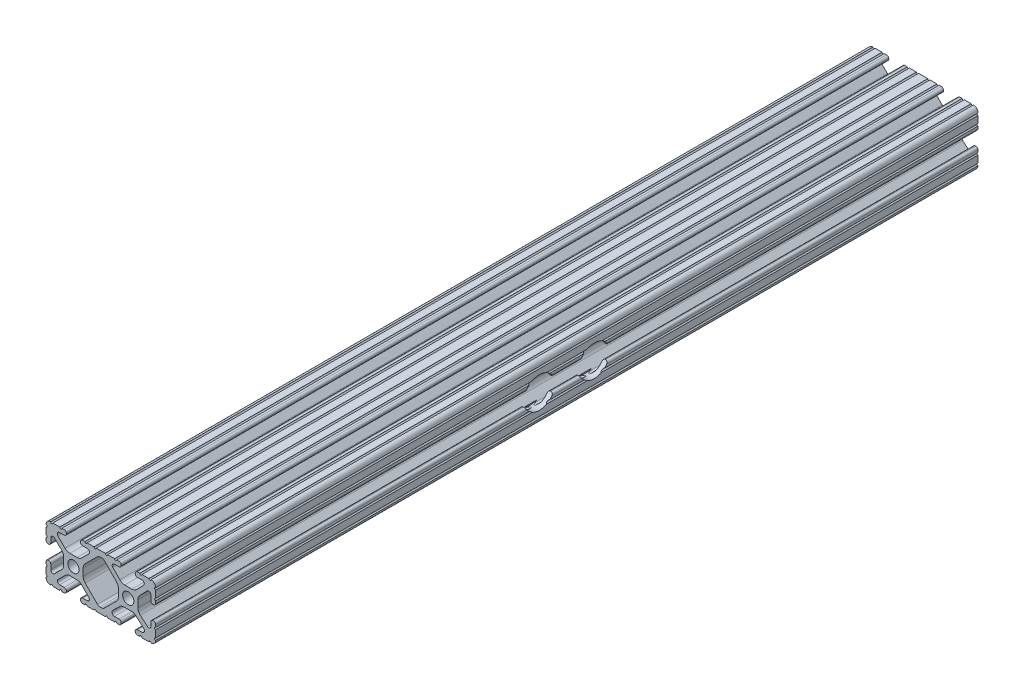
from build123d import *

# Parameters (mm, degrees)
SKETCH1_R                                            = 2.6035
BOSS_EXTRUDE1_DEPTH                                  = 190.5
CBORE_FOR_1_4_BINDING_HEAD_MACHINE_SCREW_D           = 6.7564
CBORE_FOR_1_4_BINDING_HEAD_MACHINE_SCREW_CBORE_D     = 14.2875
CBORE_FOR_1_4_BINDING_HEAD_MACHINE_SCREW_CBORE_DEPTH = 4.191


with BuildPart() as part:
    # Sketch1 → Boss-Extrude1 (new body, symmetric)
    with BuildSketch(Plane.XY):
        with BuildLine():
            Line((18.01710265, 12.7), (16.98745015, 12.7))
            ThreePointArc((16.98745015, 12.7), (16.245730386, 12.392769614), (15.9385, 11.65104985))
            Line((15.9385, 11.65104985), (15.9385, 11.53922))
            ThreePointArc((15.9385, 11.53922), (16.245750844, 10.797450844), (16.98752, 10.4902))
            Line((16.98752, 10.4902), (19.116384363, 10.4902))
            ThreePointArc((19.116384363, 10.4902), (20.052502933, 9.869096983), (19.844087081, 8.765172272))
            Line((19.844087081, 8.765172272), (16.618993479, 5.455112286))
            ThreePointArc((16.618993479, 5.455112286), (15.578994274, 4.745442459), (14.344932584, 4.4958))
            Line((14.344932584, 4.4958), (11.083317835, 4.4958))
            ThreePointArc((11.083317835, 4.4958), (9.854330953, 4.743306833), (8.816955189, 5.447238587))
            Line((8.816955189, 5.447238587), (5.564154119, 8.762652677))
            ThreePointArc((5.564154119, 8.762652677), (5.352591412, 9.867473037), (6.289393385, 10.4902))
            Line((6.289393385, 10.4902), (8.41248, 10.4902))
            ThreePointArc((8.41248, 10.4902), (9.154249156, 10.797450844), (9.4615, 11.53922))
            Line((9.4615, 11.53922), (9.4615, 11.65104985))
            ThreePointArc((9.4615, 11.65104985), (9.154269614, 12.392769614), (8.41254985, 12.7))
            Line((8.41254985, 12.7), (7.38288465, 12.7))
            ThreePointArc((7.38288465, 12.7), (6.87488465, 12.192), (6.36688465, 12.7))
            Line((6.36688465, 12.7), (3.14958095, 12.7))
            ThreePointArc((3.14958095, 12.7), (2.64158095, 12.192), (2.13358095, 12.7))
            Line((2.13358095, 12.7), (-2.13358095, 12.7))
            ThreePointArc((-2.13358095, 12.7), (-2.64158095, 12.192), (-3.14958095, 12.7))
            Line((-3.14958095, 12.7), (-6.36689735, 12.7))
            ThreePointArc((-6.36689735, 12.7), (-6.87489735, 12.192), (-7.38289735, 12.7))
            Line((-7.38289735, 12.7), (-8.41254985, 12.7))
            ThreePointArc((-8.41254985, 12.7), (-9.154269614, 12.392769614), (-9.4615, 11.65104985))
            Line((-9.4615, 11.65104985), (-9.4615, 11.53922))
            ThreePointArc((-9.4615, 11.53922), (-9.154249156, 10.797450844), (-8.41248, 10.4902))
            Line((-8.41248, 10.4902), (-6.283641037, 10.4902))
            ThreePointArc((-6.283641037, 10.4902), (-5.297291557, 9.829633109), (-5.532576693, 8.666071843))
            Line((-5.532576693, 8.666071843), (-8.809985098, 5.416263103))
            ThreePointArc((-8.809985098, 5.416263103), (-9.836720513, 4.734920264), (-11.045536121, 4.4958))
            Line((-11.045536121, 4.4958), (-14.354463879, 4.4958))
            ThreePointArc((-14.354463879, 4.4958), (-15.563279487, 4.734920264), (-16.590014902, 5.416263103))
            Line((-16.590014902, 5.416263103), (-19.867423307, 8.666071843))
            ThreePointArc((-19.867423307, 8.666071843), (-20.102708443, 9.829633109), (-19.116358963, 10.4902))
            Line((-19.116358963, 10.4902), (-16.98752, 10.4902))
            ThreePointArc((-16.98752, 10.4902), (-16.245750844, 10.797450844), (-15.9385, 11.53922))
            Line((-15.9385, 11.53922), (-15.9385, 11.65104985))
            ThreePointArc((-15.9385, 11.65104985), (-16.245730386, 12.392769614), (-16.98745015, 12.7))
            Line((-16.98745015, 12.7), (-18.01711535, 12.7))
            ThreePointArc((-18.01711535, 12.7), (-18.52511535, 12.192), (-19.03311535, 12.7))
            Line((-19.03311535, 12.7), (-22.2504, 12.7))
            ThreePointArc((-22.2504, 12.7), (-22.758323491, 12.192000006), (-23.266399977, 12.699846982))
            ThreePointArc((-23.266399977, 12.699846982), (-24.782522516, 12.082522516), (-25.399846982, 10.566399977))
            ThreePointArc((-25.399846982, 10.566399977), (-24.892000006, 10.058323491), (-25.4, 9.5504))
            Line((-25.4, 9.5504), (-25.4, 6.3330836))
            ThreePointArc((-25.4, 6.3330836), (-24.892, 5.8250836), (-25.4, 5.3170836))
            Line((-25.4, 5.3170836), (-25.4, 4.237520184))
            ThreePointArc((-25.4, 4.237520184), (-25.107393763, 3.531106237), (-24.400979816, 3.2385))
            Line((-24.400979816, 3.2385), (-24.23922, 3.2385))
            ThreePointArc((-24.23922, 3.2385), (-23.497450844, 3.545750844), (-23.1902, 4.28752))
            Line((-23.1902, 4.28752), (-23.1902, 6.334741132))
            ThreePointArc((-23.1902, 6.334741132), (-22.556026952, 7.286023527), (-21.434002553, 7.066535717))
            Line((-21.434002553, 7.066535717), (-18.147950853, 3.808156468))
            ThreePointArc((-18.147950853, 3.808156468), (-17.452759693, 2.774838327), (-17.208501877, 1.553619571))
            Line((-17.208501877, 1.553619571), (-17.208501877, -1.695179196))
            ThreePointArc((-17.208501877, -1.695179196), (-17.450738657, -2.911536421), (-18.140486065, -3.942289578))
            Line((-18.140486065, -3.942289578), (-21.431579576, -7.227386226))
            ThreePointArc((-21.431579576, -7.227386226), (-22.55444896, -7.449940594), (-23.1902, -6.498002195))
            Line((-23.1902, -6.498002195), (-23.1902, -4.28752))
            ThreePointArc((-23.1902, -4.28752), (-23.497450844, -3.545750844), (-24.23922, -3.2385))
            Line((-24.23922, -3.2385), (-24.35098, -3.2385))
            ThreePointArc((-24.35098, -3.2385), (-25.092749156, -3.545750844), (-25.4, -4.28752))
            Line((-25.4, -4.28752), (-25.4, -5.3171344))
            ThreePointArc((-25.4, -5.3171344), (-24.892, -5.8251344), (-25.4, -6.3331344))
            Line((-25.4, -6.3331344), (-25.4, -9.5504))
            ThreePointArc((-25.4, -9.5504), (-24.892000006, -10.058323491), (-25.399846982, -10.566399977))
            ThreePointArc((-25.399846982, -10.566399977), (-24.782522516, -12.082522516), (-23.266399977, -12.699846982))
            ThreePointArc((-23.266399977, -12.699846982), (-22.758323491, -12.192000006), (-22.2504, -12.7))
            Line((-22.2504, -12.7), (-19.03308995, -12.7))
            ThreePointArc((-19.03308995, -12.7), (-18.52508995, -12.192), (-18.01708995, -12.7))
            Line((-18.01708995, -12.7), (-16.9874692, -12.7))
            ThreePointArc((-16.9874692, -12.7), (-16.245700044, -12.392749156), (-15.9384492, -11.65098))
            Line((-15.9384492, -11.65098), (-15.9384492, -11.53922))
            ThreePointArc((-15.9384492, -11.53922), (-16.245700044, -10.797450844), (-16.9874692, -10.4902))
            Line((-16.9874692, -10.4902), (-19.116358963, -10.4902))
            ThreePointArc((-19.116358963, -10.4902), (-20.055197748, -9.862578342), (-19.834124023, -8.755124678))
            Line((-19.834124023, -8.755124678), (-16.49660751, -5.423689618))
            ThreePointArc((-16.49660751, -5.423689618), (-15.467274017, -4.736928798), (-14.253591699, -4.4958))
            Line((-14.253591699, -4.4958), (-11.146408301, -4.4958))
            ThreePointArc((-11.146408301, -4.4958), (-9.932725983, -4.736928798), (-8.90339249, -5.423689618))
            Line((-8.90339249, -5.423689618), (-5.565875977, -8.755124678))
            ThreePointArc((-5.565875977, -8.755124678), (-5.344802252, -9.862578342), (-6.283641037, -10.4902))
            Line((-6.283641037, -10.4902), (-8.4125308, -10.4902))
            ThreePointArc((-8.4125308, -10.4902), (-9.154299956, -10.797450844), (-9.4615508, -11.53922))
            Line((-9.4615508, -11.53922), (-9.4615508, -11.65098))
            ThreePointArc((-9.4615508, -11.65098), (-9.154299956, -12.392749156), (-8.4125308, -12.7))
            Line((-8.4125308, -12.7), (-7.38287195, -12.7))
            ThreePointArc((-7.38287195, -12.7), (-6.87487195, -12.192), (-6.36687195, -12.7))
            Line((-6.36687195, -12.7), (-3.14960635, -12.7))
            ThreePointArc((-3.14960635, -12.7), (-2.64160635, -12.192), (-2.13360635, -12.7))
            Line((-2.13360635, -12.7), (2.13360635, -12.7))
            ThreePointArc((2.13360635, -12.7), (2.64159365, -12.1920127), (3.14958095, -12.7))
            Line((3.14958095, -12.7), (6.36691005, -12.7))
            ThreePointArc((6.36691005, -12.7), (6.87491005, -12.192), (7.38291005, -12.7))
            Line((7.38291005, -12.7), (8.4125308, -12.7))
            ThreePointArc((8.4125308, -12.7), (9.154299956, -12.392749156), (9.4615508, -11.65098))
            Line((9.4615508, -11.65098), (9.4615508, -11.53922))
            ThreePointArc((9.4615508, -11.53922), (9.154299956, -10.797450844), (8.4125308, -10.4902))
            Line((8.4125308, -10.4902), (6.289393385, -10.4902))
            ThreePointArc((6.289393385, -10.4902), (5.231590322, -9.783049717), (5.480677245, -8.535265862))
            Line((5.480677245, -8.535265862), (8.597933595, -5.423689618))
            ThreePointArc((8.597933595, -5.423689618), (9.627267088, -4.736928798), (10.840949406, -4.4958))
            Line((10.840949406, -4.4958), (14.102564155, -4.4958))
            ThreePointArc((14.102564155, -4.4958), (15.215927525, -4.697410182), (16.187895372, -5.276636531))
            Line((16.187895372, -5.276636531), (19.868247549, -8.482246082))
            ThreePointArc((19.868247549, -8.482246082), (20.188435806, -9.746879864), (19.116384363, -10.4902))
            Line((19.116384363, -10.4902), (16.9874692, -10.4902))
            ThreePointArc((16.9874692, -10.4902), (16.245700044, -10.797450844), (15.9384492, -11.53922))
            Line((15.9384492, -11.53922), (15.9384492, -11.65098))
            ThreePointArc((15.9384492, -11.65098), (16.245700044, -12.392749156), (16.9874692, -12.7))
            Line((16.9874692, -12.7), (18.01710265, -12.7))
            ThreePointArc((18.01710265, -12.7), (18.52510265, -12.192), (19.03310265, -12.7))
            Line((19.03310265, -12.7), (22.2504, -12.7))
            ThreePointArc((22.2504, -12.7), (22.758323491, -12.192000006), (23.266399977, -12.699846982))
            ThreePointArc((23.266399977, -12.699846982), (24.782522516, -12.082522516), (25.399846982, -10.566399977))
            ThreePointArc((25.399846982, -10.566399977), (24.892000006, -10.058323492), (25.4, -9.550400001))
            Line((25.4, -9.550400001), (25.4, -6.333083592))
            ThreePointArc((25.4, -6.333083592), (24.892000001, -5.825083593), (25.4, -5.317083593))
            Line((25.4, -5.317083593), (25.4, -4.237520184))
            ThreePointArc((25.4, -4.237520184), (25.107393763, -3.531106237), (24.400979816, -3.2385))
            Line((24.400979816, -3.2385), (24.189220184, -3.2385))
            ThreePointArc((24.189220184, -3.2385), (23.482806237, -3.531106237), (23.1902, -4.237520184))
            Line((23.1902, -4.237520184), (23.1902, -6.155876159))
            ThreePointArc((23.1902, -6.155876159), (22.62232736, -7.038258539), (21.583974541, -6.886926384))
            Line((21.583974541, -6.886926384), (18.29817066, -4.024970844))
            ThreePointArc((18.29817066, -4.024970844), (17.493730985, -2.946044689), (17.208501877, -1.630807374))
            Line((17.208501877, -1.630807374), (17.208501877, 1.630807374))
            ThreePointArc((17.208501877, 1.630807374), (17.442348332, 2.82673414), (18.109440981, 3.846495088))
            Line((18.109440981, 3.846495088), (21.526346532, 7.353420386))
            ThreePointArc((21.526346532, 7.353420386), (22.585896263, 7.574939077), (23.1902, 6.676867167))
            Line((23.1902, 6.676867167), (23.1902, 4.237520184))
            ThreePointArc((23.1902, 4.237520184), (23.482806237, 3.531106237), (24.189220184, 3.2385))
            Line((24.189220184, 3.2385), (24.400979816, 3.2385))
            ThreePointArc((24.400979816, 3.2385), (25.107393763, 3.531106237), (25.4, 4.237520184))
            Line((25.4, 4.237520184), (25.4, 5.3170836))
            ThreePointArc((25.4, 5.3170836), (24.891949193, 5.825134407), (25.4, 6.333185215))
            Line((25.4, 6.333185215), (25.4, 9.550400015))
            ThreePointArc((25.4, 9.550400015), (24.892000013, 10.058323498), (25.399846982, 10.566399977))
            ThreePointArc((25.399846982, 10.566399977), (24.782522516, 12.082522516), (23.266399977, 12.699846982))
            ThreePointArc((23.266399977, 12.699846982), (22.758323491, 12.192000006), (22.2504, 12.7))
            Line((22.2504, 12.7), (19.03310265, 12.7))
            ThreePointArc((19.03310265, 12.7), (18.52510265, 12.192), (18.01710265, 12.7))
        make_face()
        with Locations((-12.7, 0)):
            Circle(SKETCH1_R, mode=Mode.SUBTRACT)
        with Locations((12.7, 0)):
            Circle(SKETCH1_R, mode=Mode.SUBTRACT)
        with BuildLine():
            Line((-7.259513935, -3.869413038), (-1.545748891, -9.572766749))
            ThreePointArc((-1.545748891, -9.572766749), (-1.035199478, -9.913400116), (-0.433213048, -10.033))
            Line((-0.433213048, -10.033), (0.433213048, -10.033))
            ThreePointArc((0.433213048, -10.033), (1.035199478, -9.913400116), (1.545748891, -9.572766749))
            Line((1.545748891, -9.572766749), (7.259513935, -3.869413038))
            ThreePointArc((7.259513935, -3.869413038), (7.949261343, -2.838659881), (8.191498123, -1.622302656))
            Line((8.191498123, -1.622302656), (8.191498123, 1.622302656))
            ThreePointArc((8.191498123, 1.622302656), (7.955573352, 2.823327967), (7.282860769, 3.845864069))
            Line((7.282860769, 3.845864069), (1.675572808, 9.561086461))
            ThreePointArc((1.675572808, 9.561086461), (1.161034429, 9.910236611), (0.551456936, 10.033))
            Line((0.551456936, 10.033), (-0.395199982, 10.033))
            ThreePointArc((-0.395199982, 10.033), (-0.994772524, 9.914396349), (-1.50403329, 9.576450301))
            Line((-1.50403329, 9.576450301), (-7.252049147, 3.876839553))
            ThreePointArc((-7.252049147, 3.876839553), (-7.947240307, 2.843521412), (-8.191498123, 1.622302656))
            Line((-8.191498123, 1.622302656), (-8.191498123, -1.622302656))
            ThreePointArc((-8.191498123, -1.622302656), (-7.949261343, -2.838659881), (-7.259513935, -3.869413038))
        make_face(mode=Mode.SUBTRACT)
    extrude(amount=BOSS_EXTRUDE1_DEPTH, both=True)

    # CBORE for 1/4 Binding Head Machine Screw1 (through all)
    with Locations(Plane(origin=(25.4, 0, 0), x_dir=(0, 0, -1), z_dir=(1, 0, 0))):
        with Locations((-12.7, 0), (12.7, 0)):
            CounterBoreHole(CBORE_FOR_1_4_BINDING_HEAD_MACHINE_SCREW_D / 2, CBORE_FOR_1_4_BINDING_HEAD_MACHINE_SCREW_CBORE_D / 2, CBORE_FOR_1_4_BINDING_HEAD_MACHINE_SCREW_CBORE_DEPTH)


solid = part.part
